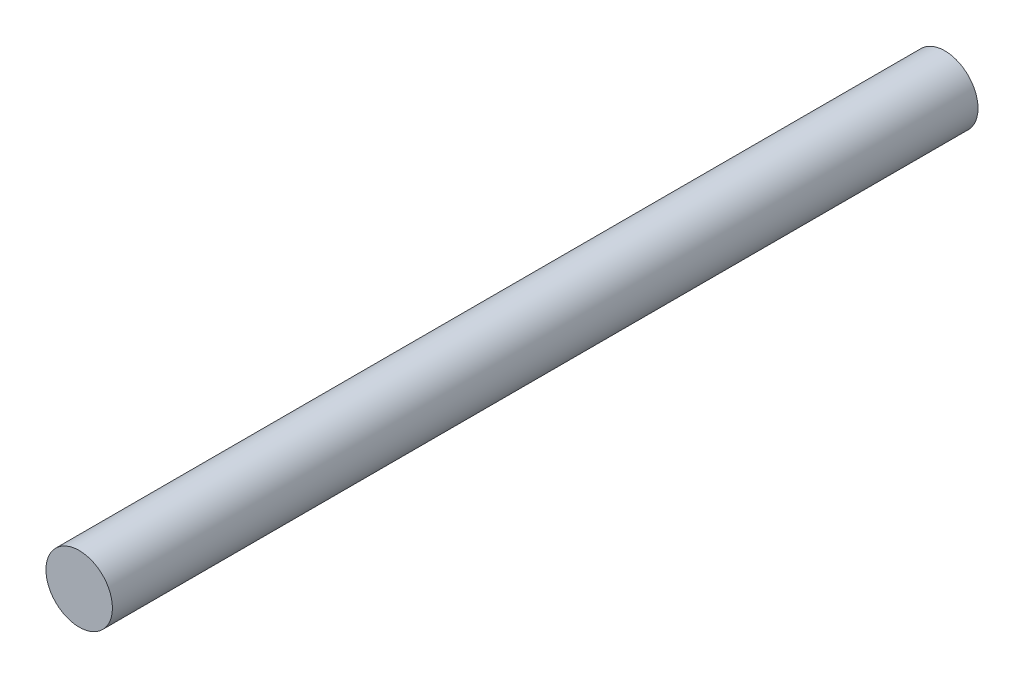
from build123d import *

# Parameters (mm, degrees)
SKETCH1_R           = 3.175
BOSS_EXTRUDE1_DEPTH = 82.677


with BuildPart() as part:
    # Sketch1 → Boss-Extrude1 (new body)
    with BuildSketch(Plane.XY):
        Circle(SKETCH1_R)
    extrude(amount=-BOSS_EXTRUDE1_DEPTH)


solid = part.part
